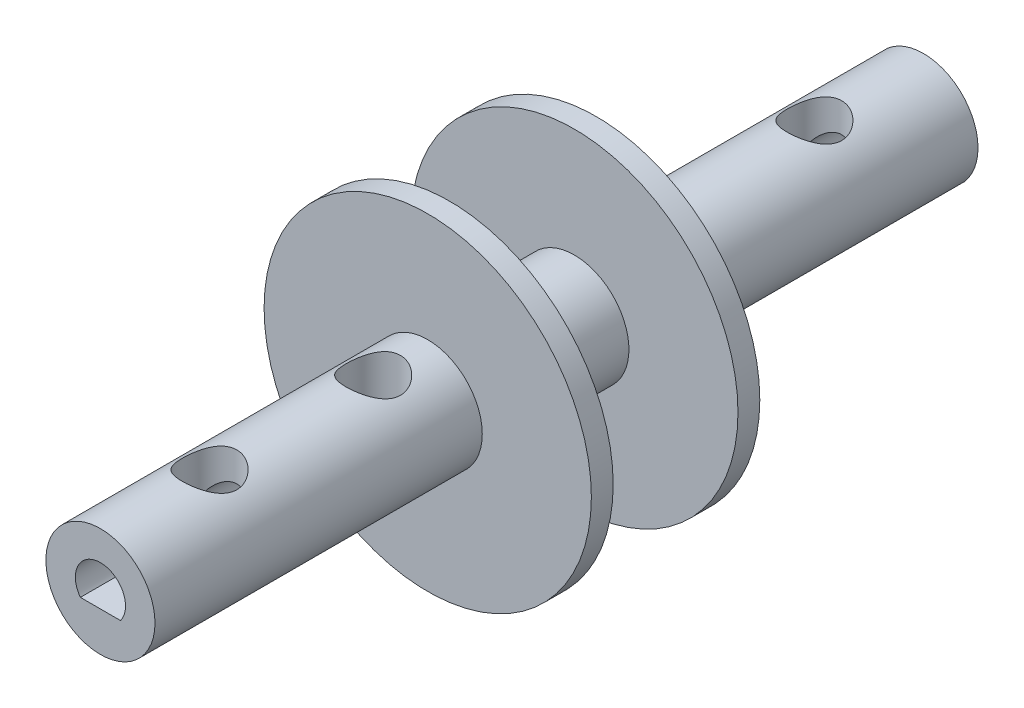
from build123d import *

# Parameters (mm, degrees)
SKETCH1_R               = 6.35
BOSS_EXTRUDE1_DEPTH     = 95.8088
SKETCH4_R               = 3.175
CUT_EXTRUDE2_DEPTH      = 7.35
CUT_EXTRUDE2_DEPTH_BACK = 7.35
SKETCH5_R               = 19.05
BOSS_EXTRUDE2_DEPTH     = 2.54
SKETCH6_R               = 19.05
BOSS_EXTRUDE3_DEPTH     = 2.54
CUT_EXTRUDE4_DEPTH      = 27.94
CUT_EXTRUDE5_DEPTH      = 27.94


with BuildPart() as part:
    # Sketch1 → Boss-Extrude1 (new body)
    with BuildSketch(Plane.XY):
        Circle(SKETCH1_R)
    extrude(amount=BOSS_EXTRUDE1_DEPTH)

    # Sketch4 → Cut-Extrude2 (cut, two sides)
    with BuildSketch(Plane(origin=(0, 0, 0), x_dir=(1, 0, 0), z_dir=(0, 1, 0))) as cut_extrude2_sk:
        with Locations((0, -83.1088)):
            Circle(SKETCH4_R)
        with Locations((0, -12.7)):
            Circle(SKETCH4_R)
        with Locations((0, -64.0588)):
            Circle(SKETCH4_R)
        with Locations((0, -31.75)):
            Circle(SKETCH4_R)
    extrude(amount=CUT_EXTRUDE2_DEPTH, mode=Mode.SUBTRACT)
    extrude(cut_extrude2_sk.sketch, amount=-CUT_EXTRUDE2_DEPTH_BACK, mode=Mode.SUBTRACT)

    # Sketch5 → Boss-Extrude2 (add)
    with BuildSketch(Plane.XY.offset(57.7088)):
        Circle(SKETCH5_R)
    extrude(amount=-BOSS_EXTRUDE2_DEPTH)

    # Sketch6 → Boss-Extrude3 (add)
    with BuildSketch(Plane(origin=(0, 0, 38.1), x_dir=(-1, 0, 0), z_dir=(0, 0, -1))):
        Circle(SKETCH6_R)
    extrude(amount=-BOSS_EXTRUDE3_DEPTH)

    # Sketch2 → Cut-Extrude4 (cut)
    with BuildSketch(Plane.XY.offset(95.8088)):
        with BuildLine():
            Line((-2.3368, -1.7526), (2.3368, -1.7526))
            ThreePointArc((2.3368, -1.7526), (0, 2.921), (-2.3368, -1.7526))
        make_face()
    extrude(amount=-CUT_EXTRUDE4_DEPTH, mode=Mode.SUBTRACT)

    # Sketch7 → Cut-Extrude5 (cut)
    with BuildSketch(Plane(origin=(0, 0, 0), x_dir=(-1, 0, 0), z_dir=(0, 0, -1))):
        with BuildLine():
            Line((-1.7526, 2.3368), (-1.7526, -2.3368))
            ThreePointArc((-1.7526, -2.3368), (1.306310912, -2.612621825), (2.921, 0))
            ThreePointArc((2.921, 0), (1.306310912, 2.612621825), (-1.7526, 2.3368))
        make_face()
    extrude(amount=-CUT_EXTRUDE5_DEPTH, mode=Mode.SUBTRACT)


solid = part.part
